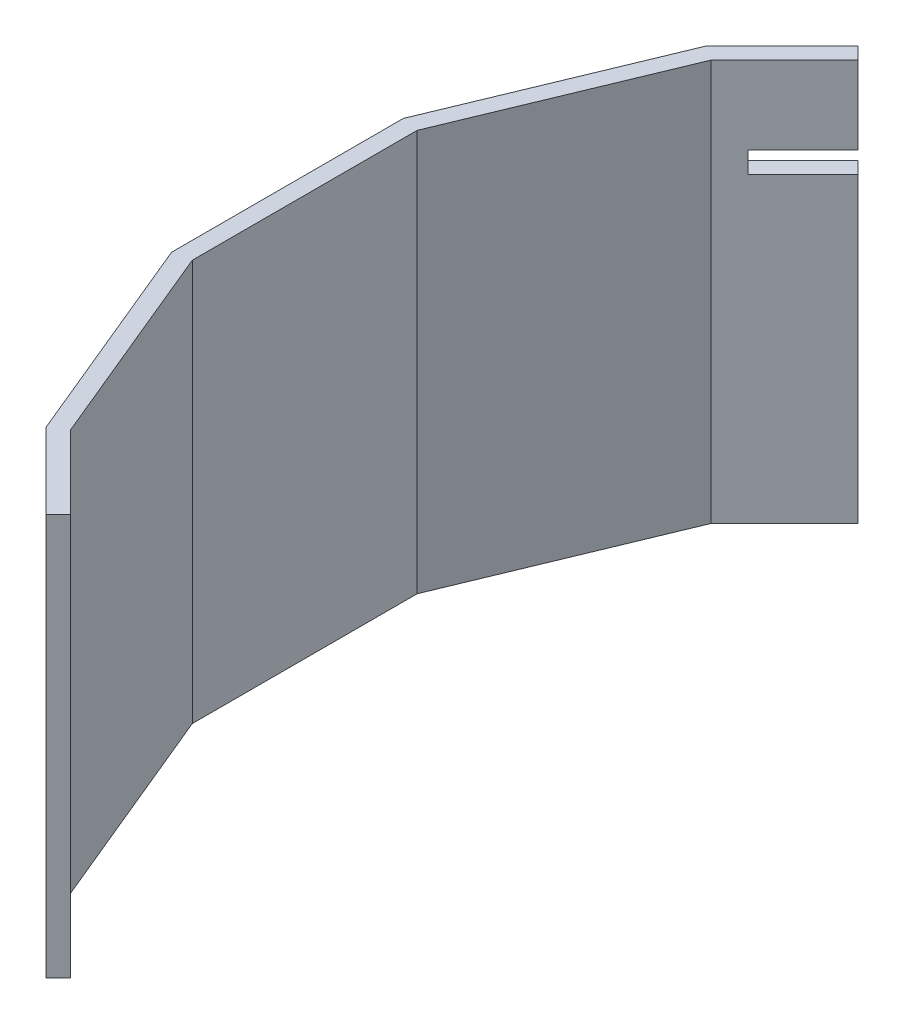
from build123d import *

# Parameters (mm, degrees)
BOSS_EXTRUDE1_DEPTH = 465
SKETCH3_W           = 180
SKETCH3_H           = 25
CUT_EXTRUDE1_DEPTH  = 40


with BuildPart() as part:
    # Sketch2 → Boss-Extrude1 (new body)
    with BuildSketch(Plane(origin=(0, 0, 0), x_dir=(1, 0, 0), z_dir=(0, 1, 0))):
        Polygon((-470.226009489, -456.083873865), (-555.28218759, -371.027695765), (-655, -130.287600634), (-655, 130.287600634), (-555.28218759, 371.027695765), (-470.226009489, 456.083873865), (-484.368145113, 470.226009489), (-572.23736889, 382.356785712), (-675, 134.265847981), (-675, -134.265847981), (-572.23736889, -382.356785712), (-484.368145113, -470.226009489), align=None)
    extrude(amount=BOSS_EXTRUDE1_DEPTH)

    # Sketch3 → Cut-Extrude1 (cut)
    with BuildSketch(Plane(origin=(-463.154941677, 0, -463.154941677), x_dir=(0.707106781, 0, -0.707106781), z_dir=(0.707106781, 0, 0.707106781))):
        with Locations((-10, 362.5)):
            Rectangle(SKETCH3_W, SKETCH3_H)
    extrude(amount=-CUT_EXTRUDE1_DEPTH, mode=Mode.SUBTRACT)


solid = part.part
